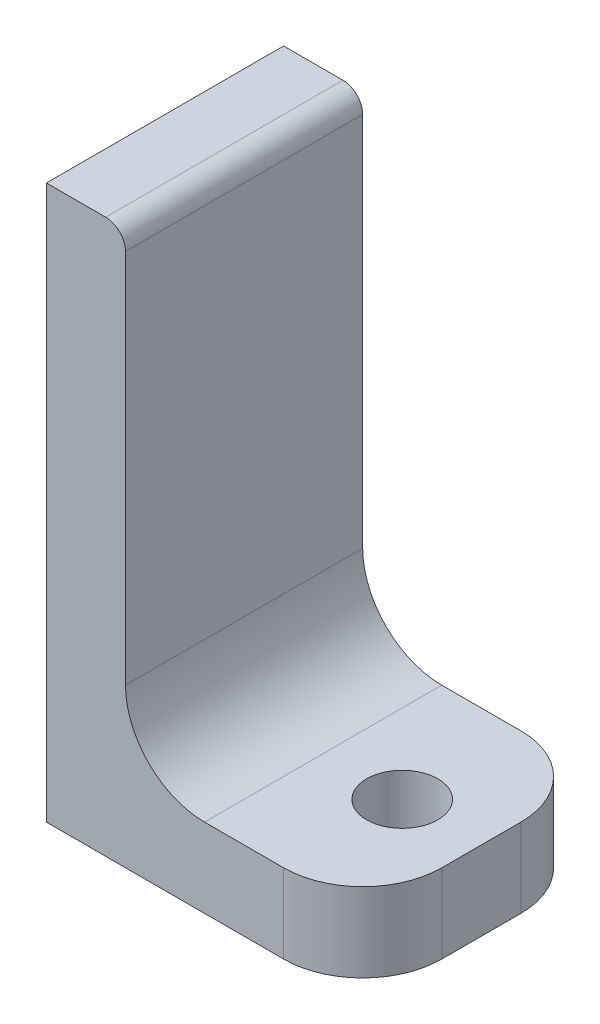
from build123d import *

# Parameters (mm, degrees)
BOSS_EXTRUDE1_DEPTH = 15
CUT_EXTRUDE1_REACH  = 7
SKETCH2_R           = 2.25
FILLET1_R           = 5


with BuildPart() as part:
    # Sketch1 → Boss-Extrude1 (new body)
    with BuildSketch(Plane.XY):
        with BuildLine():
            Line((0, 35), (0, 0))
            Line((0, 0), (20, 0))
            Line((20, 0), (20, 5))
            Line((20, 5), (10, 5))
            ThreePointArc((10, 5), (6.464466094, 6.464466094), (5, 10))
            Line((5, 10), (5, 33.75))
            ThreePointArc((5, 33.75), (4.633883476, 34.633883476), (3.75, 35))
            Line((3.75, 35), (0, 35))
        make_face()
    extrude(amount=BOSS_EXTRUDE1_DEPTH)

    # Sketch2 → Cut-Extrude1 (cut, up to next)
    with BuildSketch(Plane(origin=(0, 5, 0), x_dir=(1, 0, 0), z_dir=(0, 1, 0)), mode=Mode.PRIVATE) as cut_extrude1_sk1:
        with Locations((15, -7.5)):
            Circle(SKETCH2_R)
    cut_extrude1_tool1 = extrude(cut_extrude1_sk1.sketch, amount=-CUT_EXTRUDE1_REACH, mode=Mode.PRIVATE) & part.part
    add(cut_extrude1_tool1.solids().sort_by_distance((15, 5, 7.5))[0], mode=Mode.SUBTRACT)

    # Fillet1
    fillet1_edges = [part.edges().sort_by_distance(p)[0] for p in [
        (20, 2.5, 15),
        (20, 2.5, 0),
    ]]
    fillet(fillet1_edges, radius=FILLET1_R)


solid = part.part
